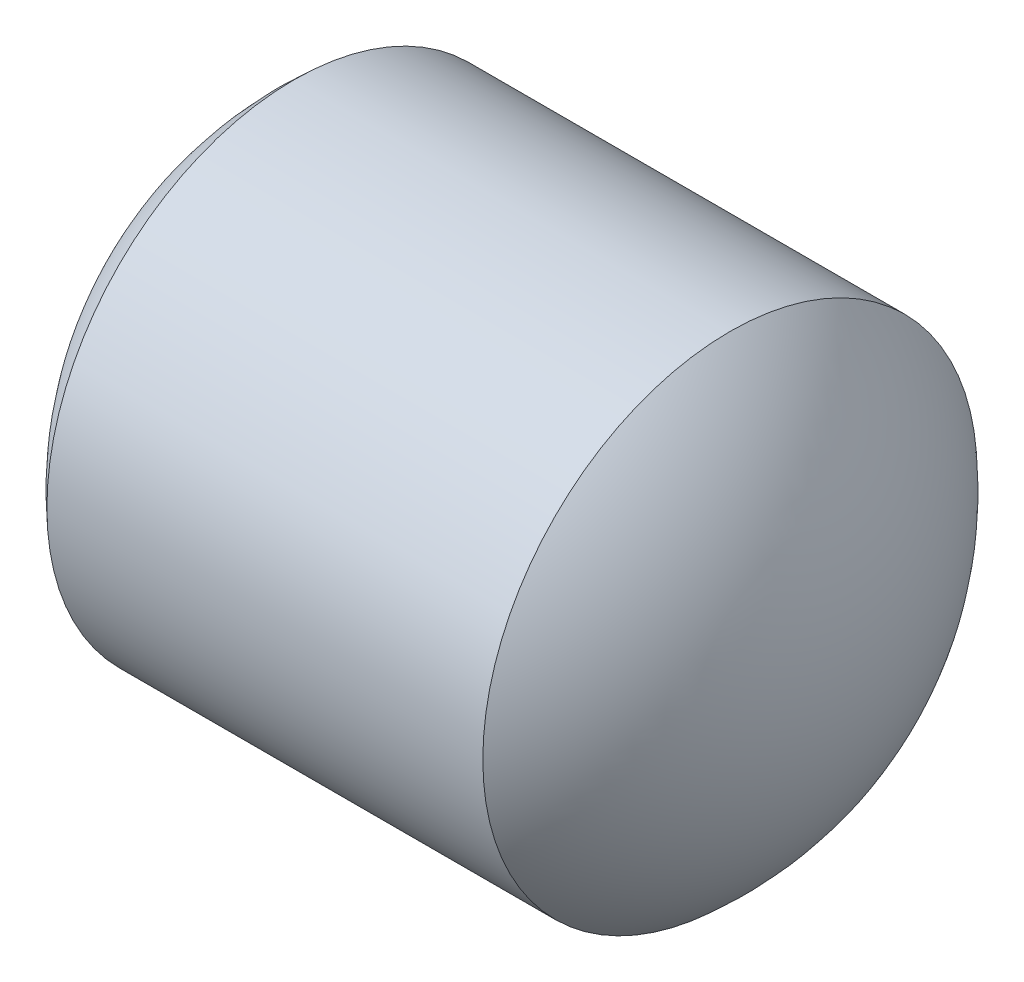
from build123d import *


with BuildPart() as part:
    # 草图1 one side → 旋转1 (revolve)
    with BuildSketch(Plane.XY):
        Polygon((231.02222423, 133.34486375), (231.02222423, 134.84486375), (229.699348574, 134.84486375), (228.376472919, 134.84486375), (228.376472919, 133.34486375), align=None)
        with BuildLine():
            Line((227.699348574, 133.34486375), (228.376472919, 133.34486375))
            Line((228.376472919, 133.34486375), (228.376472919, 134.84486375))
            ThreePointArc((228.376472919, 134.84486375), (227.876472919, 134.167739405), (227.699348574, 133.34486375))
        make_face()
        with BuildLine():
            Line((231.02222423, 133.34486375), (231.699348574, 133.34486375))
            ThreePointArc((231.699348574, 133.34486375), (231.52222423, 134.167739405), (231.02222423, 134.84486375))
            Line((231.02222423, 134.84486375), (231.02222423, 133.34486375))
        make_face()
    revolve(axis=Axis((227.543530696, 133.34486375, 0), (1, 0, 0)))


solid = part.part
